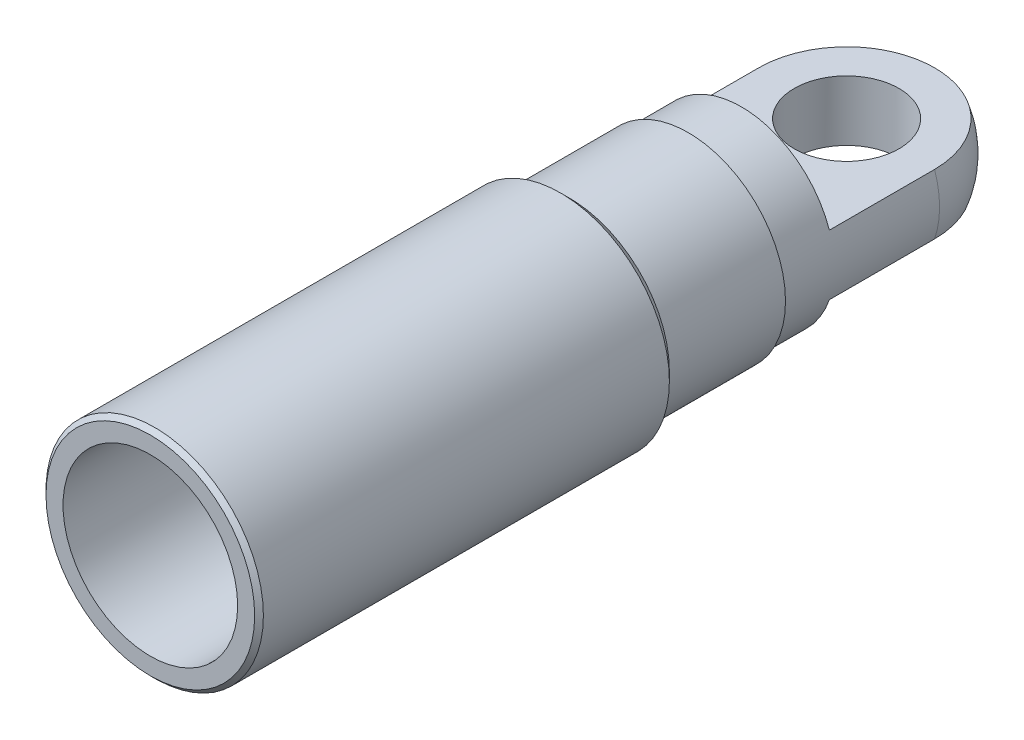
from build123d import *

# Parameters (mm, degrees)
SKETCH1_R               = 5.325
BOSS_EXTRUDE1_DEPTH     = 14.4
SKETCH2_R               = 5.575
BOSS_EXTRUDE2_DEPTH     = 6.8
SKETCH3_R               = 6.225
BOSS_EXTRUDE3_DEPTH     = 24
FILLET1_R               = 5.325
CUT_EXTRUDE1_DEPTH      = 48
CUT_EXTRUDE1_DEPTH_BACK = 48
SKETCH5_R               = 3
CUT_EXTRUDE2_DEPTH      = 48
CHAMFER1_SIZE           = 0.5
SKETCH6_R               = 5
CUT_EXTRUDE3_DEPTH      = 32.5
CHAMFER2_SIZE           = 0.25


with BuildPart() as part:
    # Sketch1 → Boss-Extrude1 (new body)
    with BuildSketch(Plane.XY):
        Circle(SKETCH1_R)
    extrude(amount=BOSS_EXTRUDE1_DEPTH)

    # Sketch2 → Boss-Extrude2 (add)
    with BuildSketch(Plane.XY.offset(14.4)):
        Circle(SKETCH2_R)
    extrude(amount=BOSS_EXTRUDE2_DEPTH)

    # Sketch3 → Boss-Extrude3 (add)
    with BuildSketch(Plane.XY.offset(21.2)):
        Circle(SKETCH3_R)
    extrude(amount=BOSS_EXTRUDE3_DEPTH)

    # Fillet1
    fillet1_edges = [part.edges().sort_by_distance(p)[0] for p in [
        (-5.325, 0, 0),
    ]]
    fillet(fillet1_edges, radius=FILLET1_R)

    # Sketch4 → Cut-Extrude1 (cut, two sides: drawn at the far end of the back side and taken through both)
    with BuildSketch(Plane(origin=(0, 0, 0), x_dir=(0, 0, -1), z_dir=(1, 0, 0)).offset(-CUT_EXTRUDE1_DEPTH_BACK)):
        Polygon((2.225204424, 1.725), (-11.35, 1.725), (-11.35, 16.315544117), (23.658725474, 16.315544117), (23.658725474, -14.317722388), (-11.35, -14.317722388), (-11.35, -1.725), (2.225204424, -1.725), align=None)
    extrude(amount=CUT_EXTRUDE1_DEPTH + CUT_EXTRUDE1_DEPTH_BACK, mode=Mode.SUBTRACT)

    # Sketch5 → Cut-Extrude2 (cut)
    with BuildSketch(Plane(origin=(0, 1.725, 0), x_dir=(1, 0, 0), z_dir=(0, 1, 0))):
        with Locations((0, -5.325)):
            Circle(SKETCH5_R)
    extrude(amount=-CUT_EXTRUDE2_DEPTH, mode=Mode.SUBTRACT)

    # Chamfer1
    chamfer1_edges = [part.edges().sort_by_distance(p)[0] for p in [
        (-6.225, 0, 21.2),
    ]]
    chamfer(chamfer1_edges, length=CHAMFER1_SIZE)

    # Sketch6 → Cut-Extrude3 (cut)
    with BuildSketch(Plane.XY.offset(45.2)):
        Circle(SKETCH6_R)
    extrude(amount=-CUT_EXTRUDE3_DEPTH, mode=Mode.SUBTRACT)

    # Chamfer2
    chamfer2_edges = [part.edges().sort_by_distance(p)[0] for p in [
        (-6.225, 0, 45.2),
    ]]
    chamfer(chamfer2_edges, length=CHAMFER2_SIZE)


solid = part.part
